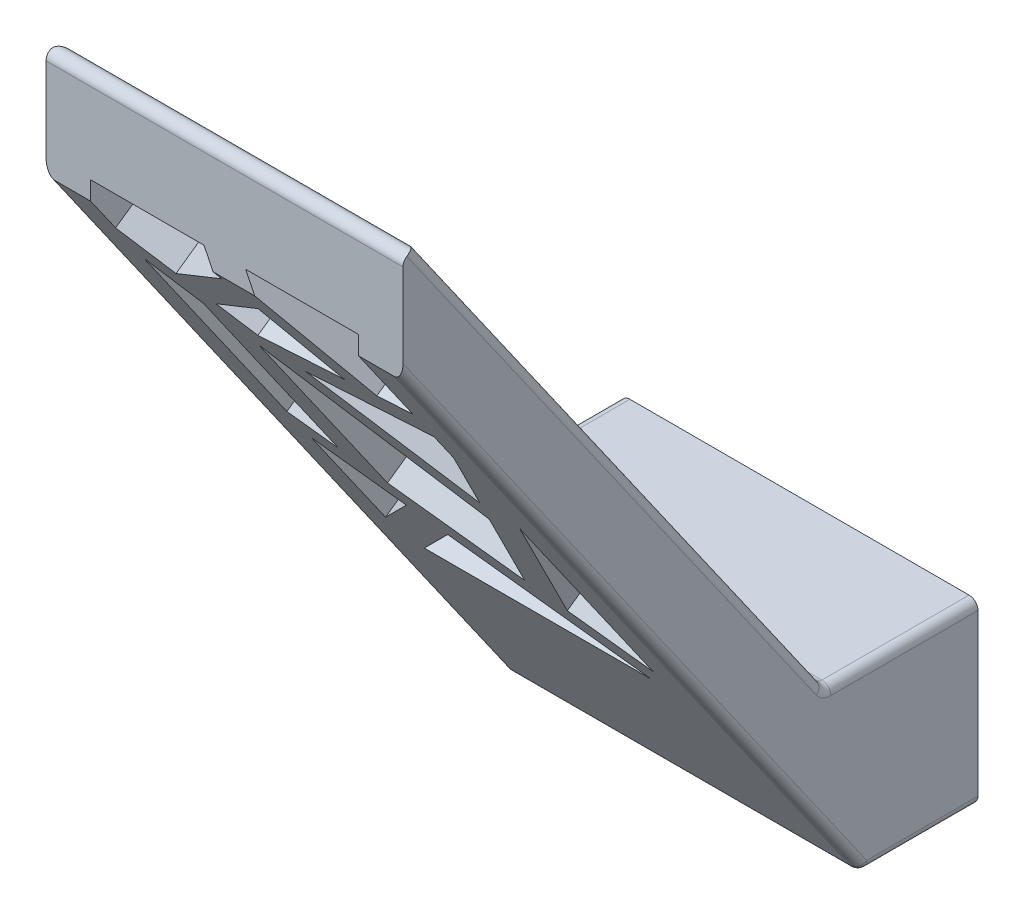
from build123d import *

# Parameters (mm, degrees)
SKETCH1_W                        = 20
SKETCH1_H                        = 10
BOSS_EXTRUDE1_DEPTH              = 5
BOSS_EXTRUDE2_DEPTH              = 20
CUT_EXTRUDE1_DEPTH               = 4.09576
FILLET1_R                        = 0.5
CUT_EXTRUDE2_REACH               = 35.208
CUT_EXTRUDE2_OFFSET_FROM_SURFACE = 1
SKETCH4_R                        = 0.5


with BuildPart() as part:
    # Sketch1 → Boss-Extrude1 (new body)
    with BuildSketch(Plane.XY):
        with Locations((-83, 16.5)):
            Rectangle(SKETCH1_W, SKETCH1_H)
    extrude(amount=BOSS_EXTRUDE1_DEPTH)

    # Sketch2 → Boss-Extrude2 (add)
    with BuildSketch(Plane.ZY.offset(93)):
        Polygon((5, 16.5), (1.498962309, 11.5), (6.498962309, 11.5), (32.208054955, 48.216389418), (32.208054955, 55.357129452), (8.501037691, 21.5), (5, 21.5), align=None)
    extrude(amount=-BOSS_EXTRUDE2_DEPTH)

    # Sketch3 → Cut-Extrude1 (cut)
    with BuildSketch(Plane(origin=(0, 3.079102266, -4.397413763), x_dir=(-1, 0, 0), z_dir=(0, 0.573576436, -0.819152044))):
        Polygon((90.5, 29.170685305), (90.5, 36.425657649), (86.606804382, 33.925761075), align=None)
        Polygon((76.580636571, 27.487763856), (89.293048323, 27.487763856), (84.912643674, 32.837907557), align=None)
        Polygon((79.020661139, 31.431370249), (75.5, 42.221469006), (75.5, 29.170685305), align=None)
        Polygon((83.682826439, 48.850072065), (75.5, 50.589500561), (75.5, 48.669091242), (77.437703633, 42.730430083), align=None)
        Polygon((77.812370658, 52.142645531), (81.816362113, 58.81968714), (75.5, 58.81968714), (75.5, 52.634187597), align=None)
        Polygon((90.5, 55.53027081), (90.5, 58.81968714), (84.148398738, 58.81968714), (83.395113947, 57.563512158), (88.334689519, 53.40846707), align=None)
        Polygon((86.899562452, 52.002175453), (85.397480311, 50.530274064), (79.880748536, 51.702969161), (82.353375162, 55.826312344), align=None)
        Polygon((90.5, 38.802476843), (90.5, 52.730114749), (88.38308654, 50.655735608), (88.38308654, 37.443165566), align=None)
        Polygon((86.38308654, 36.158926695), (80.76001209, 32.548241301), (78.130006045, 40.608666271), (86.38308654, 48.69592083), align=None)
    extrude(amount=-CUT_EXTRUDE1_DEPTH, mode=Mode.SUBTRACT)

    # Fillet1
    fillet1_edges = [part.edges().sort_by_distance(p)[0] for p in [
        (-88.38308654, 39.162299764, 20.868313128),
        (-90.5, 40.568657026, 21.853055085),
        (-89.44154327, 34.307489189, 17.468938167),
        (-89.44154327, 45.423467601, 25.252430045),
        (-85.864901733, 48.530564087, 27.428042427),
        (-90.5, 49.914103175, 28.396806926),
        (-87.324199369, 51.26136923, 29.340172774),
        (-89.41734476, 47.697797184, 26.844932764),
        (-83.771756342, 50.746870078, 28.979916589),
        (-84.626468807, 47.243065371, 26.526526121),
        (-81.117061849, 47.120517648, 26.440717281),
        (-82.639114423, 44.951387357, 24.9218759),
        (-86.148521381, 45.07393508, 25.007684739),
        (-88.553402191, 31.893356499, 15.778544259),
        (-88.553402191, 28.921893785, 13.697903667),
        (-90.5, 29.94579148, 14.414844551),
        (-83, 21.5, 8.501037691),
        (-83, 55.357129452, 32.208054955),
        (-83, 11.5, 6.498962309),
        (-93, 29.858194709, 19.353508632),
        (-93, 38.428564726, 20.354546323),
        (-73, 38.428564726, 20.354546323),
        (-73, 29.858194709, 19.353508632),
        (-80.560265036, 40.588280041, 21.866795268),
        (-76.468851816, 40.514154635, 21.814892099),
        (-79.59141322, 43.807166866, 24.120684086),
        (-75.5, 43.73304146, 24.068780918),
        (-73, 11.5, 3.249481154),
        (-76.656185329, 45.993180791, 25.651347516),
        (-93, 11.5, 3.249481154),
        (-79.814366386, 48.526613089, 27.425275908),
        (-78.658181056, 51.26136923, 29.340172774),
        (-75.5, 48.727936933, 27.566244381),
        (-93, 21.5, 4.250518846),
        (-73, 21.5, 4.250518846),
        (-87.102845999, 27.787050796, 12.903278052),
        (-80.746640123, 27.787050796, 12.903278052),
        (-82.936842447, 25.595760221, 11.368919873),
        (-77.26033057, 27.900251113, 12.982541767),
        (-77.26033057, 33.245539188, 16.725352771),
        (-75.5, 32.319616841, 16.077014963),
        (-86.38308654, 37.833613175, 19.937956762),
        (-82.256546293, 39.65611981, 21.214089647),
        (-79.445009068, 33.042417461, 16.583125407),
        (-83.571549315, 31.219910826, 15.306992522),
    ]]
    fillet(fillet1_edges, radius=FILLET1_R)

    # Cut-Extrude2: up to this face of the body (flat: up to its plane, moved by the offset)
    cut_extrude2_end = Plane(part.part.faces().sort_by_distance((-83.030327421, 27.270141069, 17.541333964))[0]).offset(-CUT_EXTRUDE2_OFFSET_FROM_SURFACE)
    # Sketch4 → Cut-Extrude2 (cut, up to the picked face)
    with BuildSketch(Plane(origin=(0, 0, 0), x_dir=(-1, 0, 0), z_dir=(0, 0, -1)), mode=Mode.PRIVATE) as cut_extrude2_sk1:
        with Locations((78, 16.5)):
            Circle(SKETCH4_R)
    cut_extrude2_tool1 = split(extrude(cut_extrude2_sk1.sketch, amount=-CUT_EXTRUDE2_REACH, mode=Mode.PRIVATE), bisect_by=cut_extrude2_end, keep=Keep.BOTH, mode=Mode.PRIVATE)
    add(cut_extrude2_tool1.solids().sort_by_distance((-78, 16.5, 0))[0], mode=Mode.SUBTRACT)
    # Sketch4 → Cut-Extrude2 (cut, up to the picked face)
    with BuildSketch(Plane(origin=(0, 0, 0), x_dir=(-1, 0, 0), z_dir=(0, 0, -1)), mode=Mode.PRIVATE) as cut_extrude2_sk2:
        with Locations((88, 16.5)):
            Circle(SKETCH4_R)
    cut_extrude2_tool2 = split(extrude(cut_extrude2_sk2.sketch, amount=-CUT_EXTRUDE2_REACH, mode=Mode.PRIVATE), bisect_by=cut_extrude2_end, keep=Keep.BOTH, mode=Mode.PRIVATE)
    add(cut_extrude2_tool2.solids().sort_by_distance((-88, 16.5, 0))[0], mode=Mode.SUBTRACT)


solid = part.part
